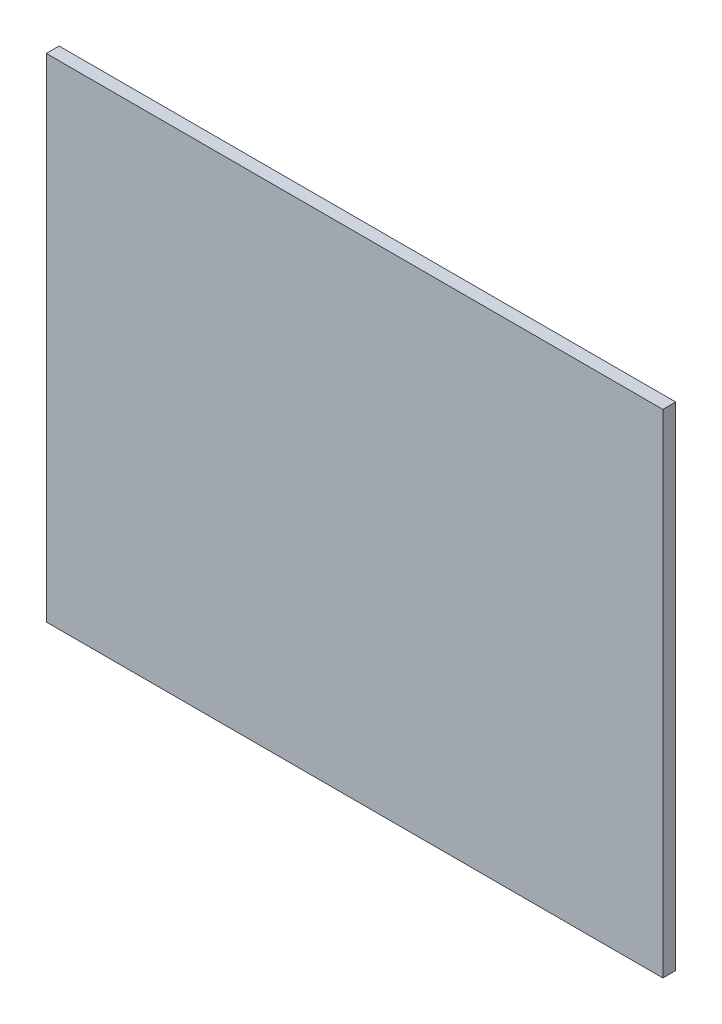
from build123d import *

# Parameters (mm, degrees)
SKETCH1_W           = 288
SKETCH1_H           = 230
BOSS_EXTRUDE1_DEPTH = 6


with BuildPart() as part:
    # Sketch1 → Boss-Extrude1 (new body)
    with BuildSketch(Plane.XY):
        with Locations((144, 115)):
            Rectangle(SKETCH1_W, SKETCH1_H)
    extrude(amount=BOSS_EXTRUDE1_DEPTH)


solid = part.part
